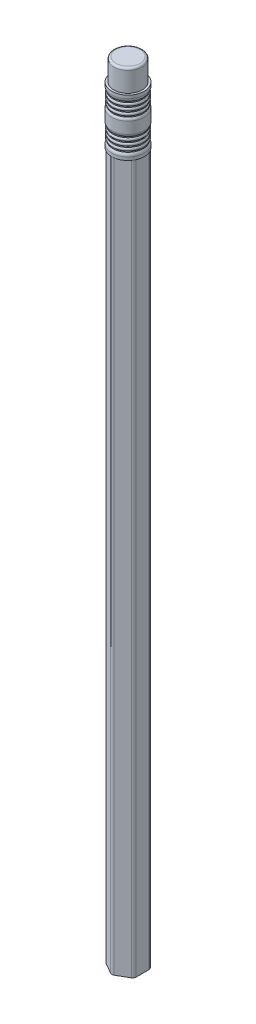
from build123d import *

# Parameters (mm, degrees)
SKETCH1_R      = 0.9398
EXTRUDE1_DEPTH = 177.8
SKETCH2_R      = 0.9525
EXTRUDE2_DEPTH = 171.45
SKETCH4_R      = 3.429
EXTRUDE3_DEPTH = 12.7
FILLET1_R      = 0.508


with BuildPart() as part:
    # Sketch1 → Extrude1 (new body)
    with BuildSketch(Plane(origin=(0, 0, 0), x_dir=(1, 0, 0), z_dir=(0, 1, 0))):
        Circle(SKETCH1_R)
    extrude(amount=EXTRUDE1_DEPTH)



with BuildPart() as body_2:
    # Sketch2 → Extrude2 (new body)
    with BuildSketch(Plane(origin=(0, 0, 0), x_dir=(1, 0, 0), z_dir=(0, 1, 0))):
        with BuildLine():
            Line((0.381, -3.812821178), (3.1115, -2.236366268))
            ThreePointArc((3.1115, -2.236366268), (3.390411358, -1.95745491), (3.4925, -1.57645491))
            Line((3.4925, -1.57645491), (3.4925, 1.57645491))
            ThreePointArc((3.4925, 1.57645491), (3.390411358, 1.95745491), (3.1115, 2.236366268))
            Line((3.1115, 2.236366268), (0.381, 3.812821178))
            ThreePointArc((0.381, 3.812821178), (0, 3.91490982), (-0.381, 3.812821178))
            Line((-0.381, 3.812821178), (-3.1115, 2.236366268))
            ThreePointArc((-3.1115, 2.236366268), (-3.390411358, 1.95745491), (-3.4925, 1.57645491))
            Line((-3.4925, 1.57645491), (-3.4925, -1.57645491))
            ThreePointArc((-3.4925, -1.57645491), (-3.390411358, -1.95745491), (-3.1115, -2.236366268))
            Line((-3.1115, -2.236366268), (-0.381, -3.812821178))
            ThreePointArc((-0.381, -3.812821178), (0, -3.91490982), (0.381, -3.812821178))
        make_face()
        Circle(SKETCH2_R, mode=Mode.SUBTRACT)
    extrude(amount=EXTRUDE2_DEPTH)

    # Sketch3 → Revolve1 (revolve)
    with BuildSketch(Plane(origin=(0, 0, 0), x_dir=(0, 0, -1), z_dir=(1, 0, 0))):
        with BuildLine():
            Line((3.6576, 172.974), (3.6576, 173.228))
            ThreePointArc((3.6576, 173.228), (3.8608, 173.609), (3.6576, 173.99))
            Line((3.6576, 173.99), (3.6576, 174.244))
            ThreePointArc((3.6576, 174.244), (3.8608, 174.625), (3.6576, 175.006))
            Line((3.6576, 175.006), (3.6576, 175.26))
            ThreePointArc((3.6576, 175.26), (3.8608, 175.641), (3.6576, 176.022))
            Line((3.6576, 176.022), (3.6576, 176.276))
            ThreePointArc((3.6576, 176.276), (3.864061607, 176.564124893), (3.937, 176.911))
            Line((3.937, 176.911), (3.937, 179.705))
            ThreePointArc((3.937, 179.705), (3.864061607, 180.051875107), (3.6576, 180.34))
            Line((3.6576, 180.34), (3.6576, 180.594))
            ThreePointArc((3.6576, 180.594), (3.8608, 180.975), (3.6576, 181.356))
            Line((3.6576, 181.356), (3.6576, 181.61))
            ThreePointArc((3.6576, 181.61), (3.8608, 181.991), (3.6576, 182.372))
            Line((3.6576, 182.372), (3.6576, 182.626))
            ThreePointArc((3.6576, 182.626), (3.8608, 183.007), (3.6576, 183.388))
            Line((3.6576, 183.388), (3.6576, 183.642))
            ThreePointArc((3.6576, 183.642), (3.864947957, 183.998195749), (3.937, 184.404))
            Line((3.937, 184.404), (3.937, 185.166))
            Line((3.937, 185.166), (0.9398, 185.166))
            Line((0.9398, 185.166), (0.9525, 171.45))
            Line((0.9525, 171.45), (3.937, 171.45))
            Line((3.937, 171.45), (3.937, 172.212))
            ThreePointArc((3.937, 172.212), (3.864947957, 172.617804251), (3.6576, 172.974))
        make_face()
    revolve(axis=Axis((0, 0, 0), (0, 1, 0)))


with BuildPart() as part_1:
    add(part.part)

    add(body_2.part)  # Extrude3 merges body 2
    # Sketch4 → Extrude3 (add)
    with BuildSketch(Plane(origin=(0, 177.8, 0), x_dir=(1, 0, 0), z_dir=(0, 1, 0))):
        Circle(SKETCH4_R)
    extrude(amount=EXTRUDE3_DEPTH)

    # Fillet1
    fillet1_edges = [part_1.edges().sort_by_distance(p)[0] for p in [
        (-3.429, 190.5, 0),
    ]]
    fillet(fillet1_edges, radius=FILLET1_R)


solid = part_1.part
